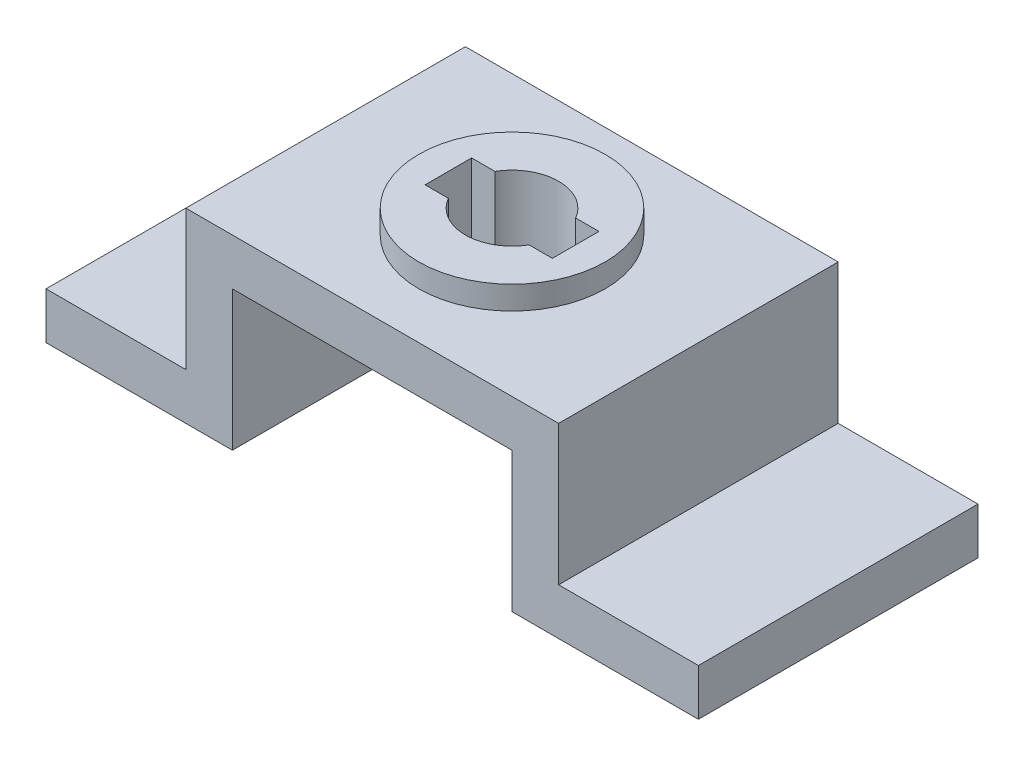
from build123d import *

# Parameters (mm, degrees)
IZIM1_W                     = 140
IZIM1_H                     = 40
Y_KSEKLIK_EKSTR_ZYON1_DEPTH = 60
IZIM2_W                     = 30
IZIM2_H                     = 60
KES_EKSTR_ZYON1_DEPTH       = 30
IZIM3_W                     = 60
IZIM3_H                     = 30
KES_EKSTR_ZYON2_DEPTH       = 158.48015748
KES_EKSTR_ZYON3_DEPTH       = 158.48015748
Y_KSEKLIK_EKSTR_ZYON2_START = 5
IZIM4_4_R                   = 20
Y_KSEKLIK_EKSTR_ZYON2_DEPTH = 5


with BuildPart() as part:
    # Çizim1 → Yükseklik-Ekstrüzyon1 (new body)
    with BuildSketch(Plane.XY):
        with Locations((70, 20)):
            Rectangle(IZIM1_W, IZIM1_H)
    extrude(amount=Y_KSEKLIK_EKSTR_ZYON1_DEPTH)

    # Çizim2 → Kes-Ekstrüzyon1 (cut)
    with BuildSketch(Plane(origin=(0, 40, 0), x_dir=(1, 0, 0), z_dir=(0, 1, 0))):
        with Locations((15, -30)):
            Rectangle(IZIM2_W, IZIM2_H)
        with Locations((125, -30)):
            Rectangle(IZIM2_W, IZIM2_H)
    extrude(amount=-KES_EKSTR_ZYON1_DEPTH, mode=Mode.SUBTRACT)

    # Çizim3 → Kes-Ekstrüzyon2 (cut, through all)
    with BuildSketch(Plane.XY.offset(60)):
        with Locations((70, 15)):
            Rectangle(IZIM3_W, IZIM3_H)
    extrude(amount=-KES_EKSTR_ZYON2_DEPTH, mode=Mode.SUBTRACT)

    # Çizim4 → Kes-Ekstrüzyon3 (cut, through all)
    with BuildSketch(Plane(origin=(0, 40, 0), x_dir=(1, 0, 0), z_dir=(0, 1, 0))):
        with BuildLine():
            Line((56.339745962, -25), (61.339745962, -25))
            ThreePointArc((61.339745962, -25), (70, -20), (78.660254038, -25))
            Line((78.660254038, -25), (83.660254038, -25))
            Line((83.660254038, -25), (83.660254038, -35))
            Line((83.660254038, -35), (78.660254038, -35))
            ThreePointArc((78.660254038, -35), (70, -40), (61.339745962, -35))
            Line((61.339745962, -35), (56.339745962, -35))
            Line((56.339745962, -35), (56.339745962, -25))
        make_face()
    extrude(amount=-KES_EKSTR_ZYON3_DEPTH, mode=Mode.SUBTRACT)

    # Çizim4<4> → Yükseklik-Ekstrüzyon2 (add)
    with BuildSketch(Plane(origin=(0, 40, 0), x_dir=(1, 0, 0), z_dir=(0, 1, 0)).offset(Y_KSEKLIK_EKSTR_ZYON2_START)):
        with Locations((70, -30)):
            Circle(IZIM4_4_R)
        with BuildLine():
            Line((56.339745962, -25), (61.339745962, -25))
            ThreePointArc((61.339745962, -25), (70, -20), (78.660254038, -25))
            Line((78.660254038, -25), (83.660254038, -25))
            Line((83.660254038, -25), (83.660254038, -35))
            Line((83.660254038, -35), (78.660254038, -35))
            ThreePointArc((78.660254038, -35), (70, -40), (61.339745962, -35))
            Line((61.339745962, -35), (56.339745962, -35))
            Line((56.339745962, -35), (56.339745962, -25))
        make_face(mode=Mode.SUBTRACT)
    extrude(amount=-Y_KSEKLIK_EKSTR_ZYON2_DEPTH)


solid = part.part
